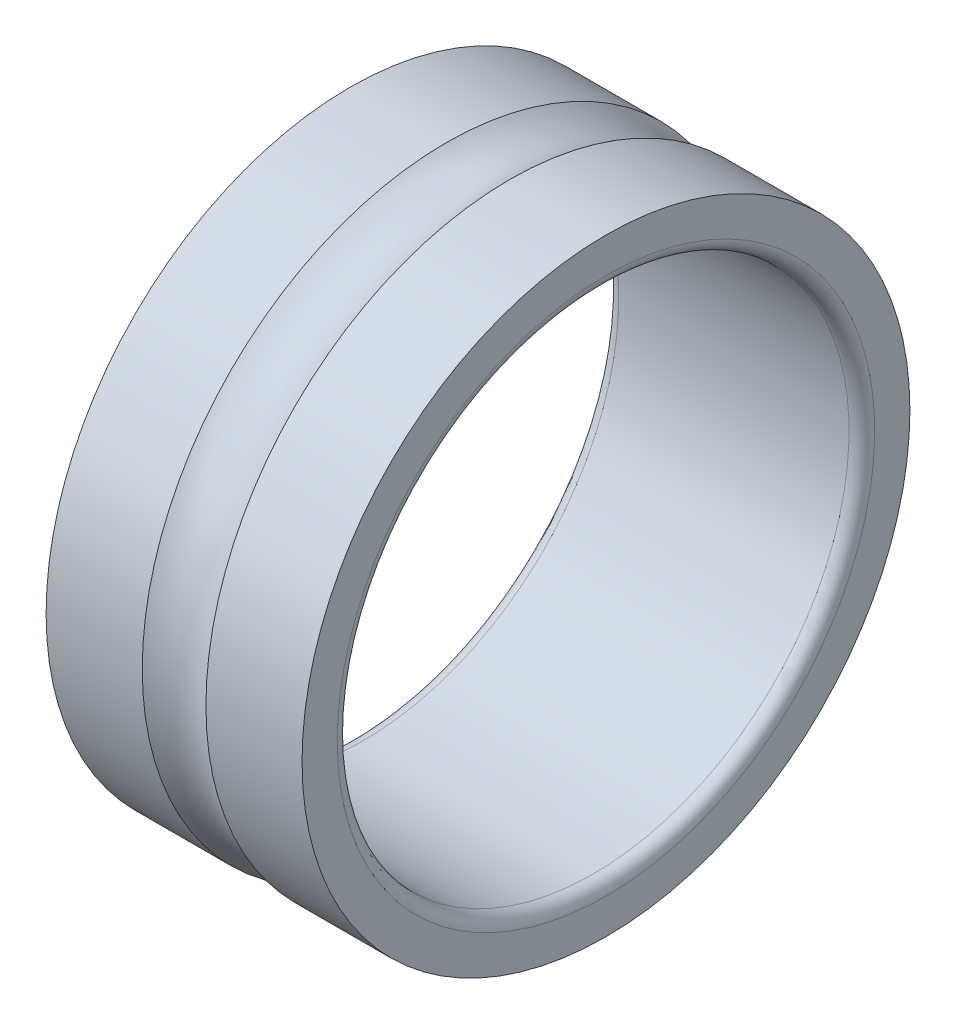
from build123d import *


with BuildPart() as part:
    # Sketch1 → Revolve1 (revolve)
    with BuildSketch(Plane.XY):
        with BuildLine():
            Line((0, 2.375), (0, 2.1))
            ThreePointArc((0, 2.1), (0.029289322, 2.029289322), (0.1, 2))
            Line((0.1, 2), (1.9, 2))
            ThreePointArc((1.9, 2), (1.970710678, 2.029289322), (2, 2.1))
            Line((2, 2.1), (2, 2.375))
            Line((2, 2.375), (1.248746859, 2.375))
            ThreePointArc((1.248746859, 2.375), (1, 2.3), (0.751253141, 2.375))
            Line((0.751253141, 2.375), (0, 2.375))
        make_face()
    revolve(axis=Axis((2, 0, 0), (-1, 0, 0)))


solid = part.part
